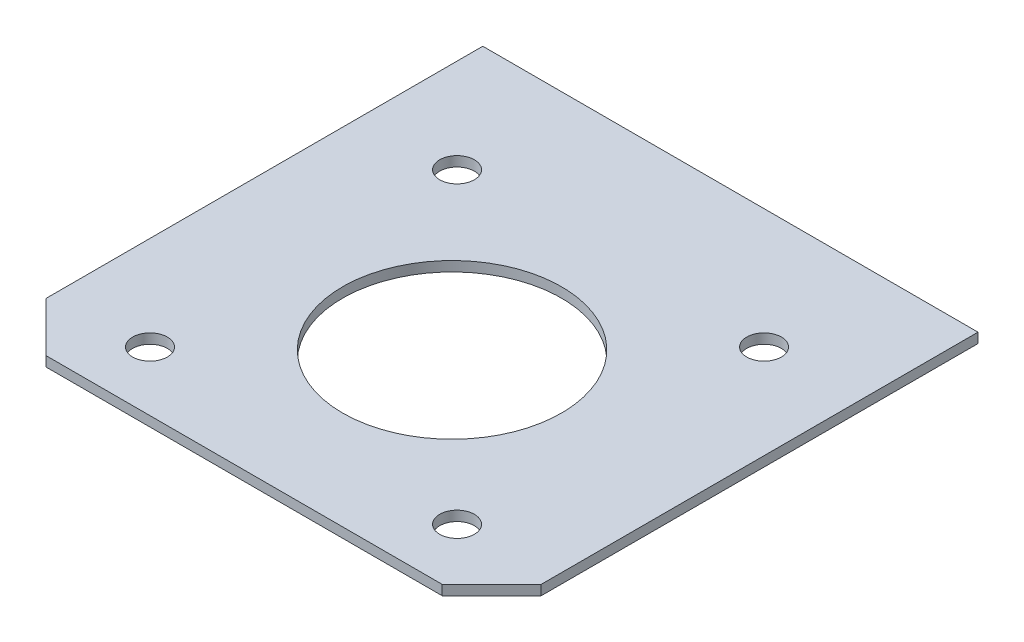
from build123d import *

# Parameters (mm, degrees)
SKETCH1_W           = 500
SKETCH1_H           = 491
SKETCH1_R           = 110.5
SKETCH1_R_2         = 17.5
BOSS_EXTRUDE1_DEPTH = 10
CHAMFER1_SIZE       = 50


with BuildPart() as part:
    # Sketch1 → Boss-Extrude1 (new body)
    with BuildSketch(Plane(origin=(0, 0, 0), x_dir=(1, 0, 0), z_dir=(0, 1, 0))):
        Rectangle(SKETCH1_W, SKETCH1_H)
        with Locations((0, -35.5)):
            Circle(SKETCH1_R, mode=Mode.SUBTRACT)
        with Locations((-155, 124.5)):
            Circle(SKETCH1_R_2, mode=Mode.SUBTRACT)
        with Locations((155, 124.5)):
            Circle(SKETCH1_R_2, mode=Mode.SUBTRACT)
        with Locations((-155, -185.5)):
            Circle(SKETCH1_R_2, mode=Mode.SUBTRACT)
        with Locations((155, -185.5)):
            Circle(SKETCH1_R_2, mode=Mode.SUBTRACT)
    extrude(amount=BOSS_EXTRUDE1_DEPTH)

    # Chamfer1
    chamfer1_edges = [part.edges().sort_by_distance(p)[0] for p in [
        (250, 5, 245.5),
        (-250, 5, 245.5),
    ]]
    chamfer(chamfer1_edges, length=CHAMFER1_SIZE)


solid = part.part
